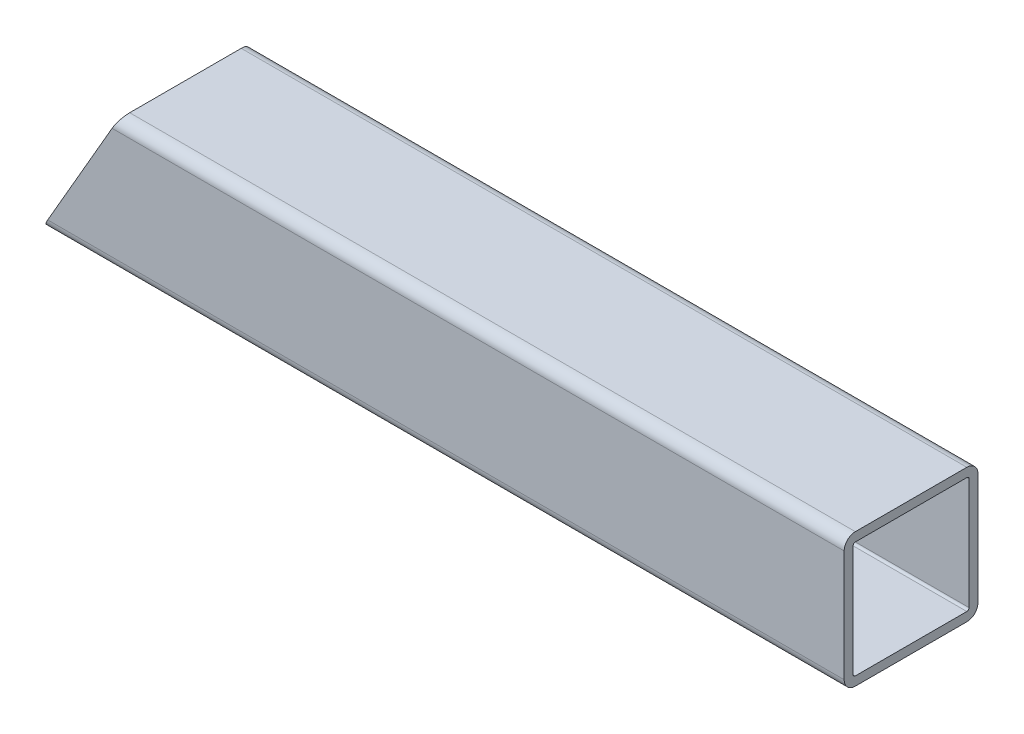
from build123d import *

# Parameters (mm, degrees)
EXTRUDE_THIN1_DEPTH     = 114.3
CUT_EXTRUDE1_DEPTH      = 1
CUT_EXTRUDE1_DEPTH_BACK = 39.1


with BuildPart() as part:
    # Sketch1 → Extrude-Thin1 (new body, symmetric)
    with BuildSketch(Plane(origin=(0, 0, 0), x_dir=(0, 0, -1), z_dir=(1, 0, 0))):
        with BuildLine():
            Line((-15.875, 19.05), (15.875, 19.05))
            ThreePointArc((15.875, 19.05), (18.12006403, 18.12006403), (19.05, 15.875))
            Line((19.05, 15.875), (19.05, -15.875))
            ThreePointArc((19.05, -15.875), (18.12006403, -18.12006403), (15.875, -19.05))
            Line((15.875, -19.05), (-15.875, -19.05))
            ThreePointArc((-15.875, -19.05), (-18.12006403, -18.12006403), (-19.05, -15.875))
            Line((-19.05, -15.875), (-19.05, 15.875))
            ThreePointArc((-19.05, 15.875), (-18.12006403, 18.12006403), (-15.875, 19.05))
        make_face()
        with BuildLine():
            Line((-15.875, 16.51), (15.875, 16.51))
            ThreePointArc((15.875, 16.51), (16.324012806, 16.324012806), (16.51, 15.875))
            Line((16.51, 15.875), (16.51, -15.875))
            ThreePointArc((16.51, -15.875), (16.324012806, -16.324012806), (15.875, -16.51))
            Line((15.875, -16.51), (-15.875, -16.51))
            ThreePointArc((-15.875, -16.51), (-16.324012806, -16.324012806), (-16.51, -15.875))
            Line((-16.51, -15.875), (-16.51, 15.875))
            ThreePointArc((-16.51, 15.875), (-16.324012806, 16.324012806), (-15.875, 16.51))
        make_face(mode=Mode.SUBTRACT)
    extrude(amount=EXTRUDE_THIN1_DEPTH, both=True)

    # Sketch2 → Cut-Extrude1 (cut, two sides)
    with BuildSketch(Plane.XY.offset(19.05)) as cut_extrude1_sk:
        Polygon((-351.053252404, -429.118662022), (-114.3, -19.05), (-92.302954744, 19.05), (144.45029766, 429.118662022), (-675.687026383, 902.62516683), (-1171.190576447, 44.387842787), align=None)
    extrude(amount=CUT_EXTRUDE1_DEPTH, mode=Mode.SUBTRACT)
    extrude(cut_extrude1_sk.sketch, amount=-CUT_EXTRUDE1_DEPTH_BACK, mode=Mode.SUBTRACT)


solid = part.part
